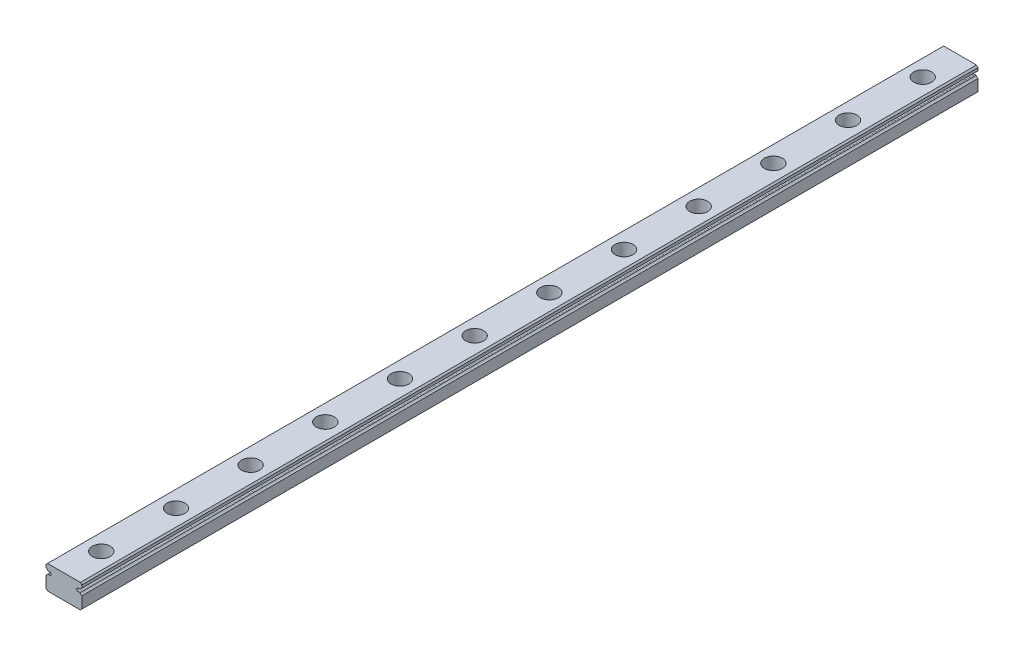
from build123d import *

# Parameters (mm, degrees)
BOSS_EXTRUDE1_DEPTH = 300
SKETCH2_R           = 3
CUT_EXTRUDE1_DEPTH  = 4.5
SKETCH3_R           = 1.75
CUT_EXTRUDE2_DEPTH  = 301.093735356
LPATTERN1_COUNT     = 14
LPATTERN1_PITCH     = 25


with BuildPart() as part:
    # Sketch1 → Boss-Extrude1 (new body)
    with BuildSketch(Plane.XY):
        with BuildLine():
            Line((-5.5, -4), (5.5, -4))
            Line((5.5, -4), (6, -3.5))
            Line((6, -3.5), (6, 0.368911094))
            ThreePointArc((6, 0.368911094), (5.63354293, 0.61854293), (5.383911094, 0.985))
            Line((5.383911094, 0.985), (4.92112495, 0.985))
            ThreePointArc((4.92112495, 0.985), (4.265, 1.46), (4.92112495, 1.935))
            Line((4.92112495, 1.935), (5.383911094, 1.935))
            ThreePointArc((5.383911094, 1.935), (5.63354293, 2.30145707), (6, 2.551088906))
            Line((6, 2.551088906), (6, 3.5))
            Line((6, 3.5), (5.5, 4))
            Line((5.5, 4), (-5.5, 4))
            Line((-5.5, 4), (-6, 3.5))
            Line((-6, 3.5), (-6, 2.551088906))
            ThreePointArc((-6, 2.551088906), (-5.63354293, 2.30145707), (-5.383911094, 1.935))
            Line((-5.383911094, 1.935), (-4.92112495, 1.935))
            ThreePointArc((-4.92112495, 1.935), (-4.265, 1.46), (-4.92112495, 0.985))
            Line((-4.92112495, 0.985), (-5.383911094, 0.985))
            ThreePointArc((-5.383911094, 0.985), (-5.63354293, 0.61854293), (-6, 0.368911094))
            Line((-6, 0.368911094), (-6, -3.5))
            Line((-6, -3.5), (-5.5, -4))
        make_face()
    extrude(amount=BOSS_EXTRUDE1_DEPTH)

    # Sketch2 → Cut-Extrude1 (cut)
    with BuildSketch(Plane(origin=(0, 4, 0), x_dir=(1, 0, 0), z_dir=(0, 1, 0))):
        with Locations((0, -12.5)):
            Circle(SKETCH2_R)
    cut_extrude1 = extrude(amount=-CUT_EXTRUDE1_DEPTH, mode=Mode.SUBTRACT)

    # Sketch3 → Cut-Extrude2 (cut, through all)
    with BuildSketch(Plane(origin=(0, -0.5, 0), x_dir=(1, 0, 0), z_dir=(0, 1, 0))):
        with Locations((0, -12.5)):
            Circle(SKETCH3_R)
    cut_extrude2 = extrude(amount=-CUT_EXTRUDE2_DEPTH, mode=Mode.SUBTRACT)

    # LPattern1: Cut-Extrude1, Cut-Extrude2 ×14
    with Locations(*[(0, 0, i * LPATTERN1_PITCH) for i in range(1, LPATTERN1_COUNT)]):
        add(cut_extrude1, mode=Mode.SUBTRACT)
        add(cut_extrude2, mode=Mode.SUBTRACT)


solid = part.part
